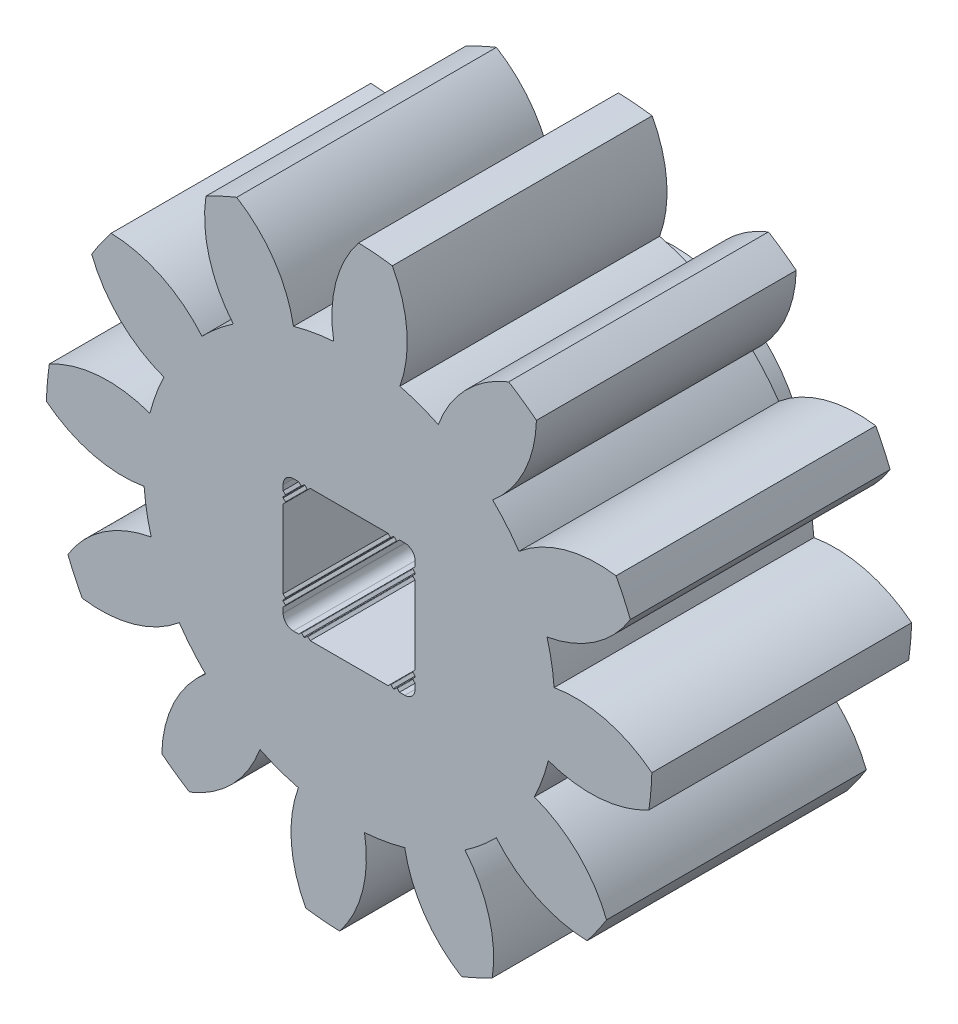
from build123d import *

# Parameters (mm, degrees)
SKETCH1_W            = 7.404
SKETCH1_H            = 6.35
CUT_EXTRUDE1_DEPTH   = 7.35
CUT_EXTRUDE2_DEPTH   = 7.35
CUT_EXTRUDE3_DEPTH   = 7.35
CUT_EXTRUDE4_DEPTH   = 7.35
CUT_EXTRUDE5_DEPTH   = 7.35
CUT_EXTRUDE6_DEPTH   = 7.35
CUT_EXTRUDE7_DEPTH   = 7.35
CUT_EXTRUDE8_DEPTH   = 7.35
CUT_EXTRUDE9_DEPTH   = 7.35
CUT_EXTRUDE10_DEPTH  = 7.35
CUT_EXTRUDE11_DEPTH  = 7.35
CUT_EXTRUDE12_DEPTH  = 7.35
SKETCH15_R           = 3.25
BOSS_EXTRUDE2_DEPTH  = 1.5875
CUT_EXTRUDE13_DEPTH  = 8.9375
FILLET1_R            = 0.0127
CHAMFER1_SIZE        = 0.017960512
CHAMFER2_SIZE        = 0.017990274
CHAMFER2_EDGE_2_SIZE = 0.017990274
CHAMFER2_EDGE_3_SIZE = 0.017990274
CHAMFER2_EDGE_4_SIZE = 0.017990274
FILLET2_R            = 0.25


with BuildPart() as part:
    # Sketch1 → Revolve1 (revolve)
    with BuildSketch(Plane(origin=(0, 0, 0), x_dir=(1, 0, 0), z_dir=(0, 1, 0))):
        with Locations((3.702, 0)):
            Rectangle(SKETCH1_W, SKETCH1_H)
    revolve(axis=Axis((0, 0, -3.175), (0, 0, 1)))

    # Sketch2 → Cut-Extrude1 (cut, through all)
    with BuildSketch(Plane(origin=(0, 0, -3.175), x_dir=(-1, 0, 0), z_dir=(0, 0, -1))):
        with BuildLine():
            ThreePointArc((1.057001873, -7.328162323), (2.532317141, -6.957484164), (3.900741532, -6.293125734))
            ThreePointArc((3.900741532, -6.293125734), (2.850773823, -5.595435975), (2.180140266, -4.527983952))
            ThreePointArc((2.180140266, -4.527983952), (1.71882223, -4.722425266), (1.240447645, -4.870004095))
            ThreePointArc((1.240447645, -4.870004095), (1.41285747, -6.118794727), (1.057001873, -7.328162323))
        make_face()
    extrude(amount=-CUT_EXTRUDE1_DEPTH, mode=Mode.SUBTRACT)

    # Sketch3 → Cut-Extrude2 (cut, through all)
    with BuildSketch(Plane(origin=(0, 0, -3.175), x_dir=(-1, 0, 0), z_dir=(0, 0, -1))):
        with BuildLine():
            ThreePointArc((-2.748690687, -6.874875672), (-1.285691107, -7.291516603), (0.231578393, -7.400377521))
            ThreePointArc((0.231578393, -7.400377521), (-0.328875436, -6.271176611), (-0.375935122, -5.011419263))
            ThreePointArc((-0.375935122, -5.011419263), (-0.872668917, -4.949151363), (-1.360742875, -4.837771086))
            ThreePointArc((-1.360742875, -4.837771086), (-1.835826903, -6.005460409), (-2.748690687, -6.874875672))
        make_face()
    extrude(amount=-CUT_EXTRUDE2_DEPTH, mode=Mode.SUBTRACT)

    # Sketch4 → Cut-Extrude3 (cut, through all)
    with BuildSketch(Plane(origin=(0, 0, -3.175), x_dir=(-1, 0, 0), z_dir=(0, 0, -1))):
        with BuildLine():
            ThreePointArc((-5.817873798, -4.579471636), (-4.759199462, -5.671793057), (-3.499635989, -6.524704127))
            ThreePointArc((-3.499635989, -6.524704127), (-3.420402788, -5.266560539), (-2.831278997, -4.15204883))
            ThreePointArc((-2.831278997, -4.15204883), (-3.230329132, -3.849756349), (-3.597323441, -3.509261221))
            ThreePointArc((-3.597323441, -3.509261221), (-4.592602939, -4.282967824), (-5.817873798, -4.579471636))
        make_face()
    extrude(amount=-CUT_EXTRUDE3_DEPTH, mode=Mode.SUBTRACT)

    # Sketch5 → Cut-Extrude4 (cut, through all)
    with BuildSketch(Plane(origin=(0, 0, -3.175), x_dir=(-1, 0, 0), z_dir=(0, 0, -1))):
        with BuildLine():
            ThreePointArc((-7.328162323, -1.057001873), (-6.957484164, -2.532317141), (-6.293125734, -3.900741532))
            ThreePointArc((-6.293125734, -3.900741532), (-5.595435975, -2.850773823), (-4.527983952, -2.180140266))
            ThreePointArc((-4.527983952, -2.180140266), (-4.722425266, -1.71882223), (-4.870004095, -1.240447645))
            ThreePointArc((-4.870004095, -1.240447645), (-6.118794727, -1.41285747), (-7.328162323, -1.057001873))
        make_face()
    extrude(amount=-CUT_EXTRUDE4_DEPTH, mode=Mode.SUBTRACT)

    # Sketch6 → Cut-Extrude5 (cut, through all)
    with BuildSketch(Plane(origin=(0, 0, -3.175), x_dir=(-1, 0, 0), z_dir=(0, 0, -1))):
        with BuildLine():
            ThreePointArc((-6.874875672, 2.748690687), (-7.291516603, 1.285691107), (-7.400377521, -0.231578393))
            ThreePointArc((-7.400377521, -0.231578393), (-6.271176611, 0.328875436), (-5.011419263, 0.375935122))
            ThreePointArc((-5.011419263, 0.375935122), (-4.949151363, 0.872668917), (-4.837771086, 1.360742875))
            ThreePointArc((-4.837771086, 1.360742875), (-6.005460409, 1.835826903), (-6.874875672, 2.748690687))
        make_face()
    extrude(amount=-CUT_EXTRUDE5_DEPTH, mode=Mode.SUBTRACT)

    # Sketch7 → Cut-Extrude6 (cut, through all)
    with BuildSketch(Plane(origin=(0, 0, -3.175), x_dir=(-1, 0, 0), z_dir=(0, 0, -1))):
        with BuildLine():
            ThreePointArc((-4.579471636, 5.817873798), (-5.671793057, 4.759199462), (-6.524704127, 3.499635989))
            ThreePointArc((-6.524704127, 3.499635989), (-5.266560539, 3.420402788), (-4.15204883, 2.831278997))
            ThreePointArc((-4.15204883, 2.831278997), (-3.849756349, 3.230329132), (-3.509261221, 3.597323441))
            ThreePointArc((-3.509261221, 3.597323441), (-4.282967824, 4.592602939), (-4.579471636, 5.817873798))
        make_face()
    extrude(amount=-CUT_EXTRUDE6_DEPTH, mode=Mode.SUBTRACT)

    # Sketch8 → Cut-Extrude7 (cut, through all)
    with BuildSketch(Plane(origin=(0, 0, -3.175), x_dir=(-1, 0, 0), z_dir=(0, 0, -1))):
        with BuildLine():
            ThreePointArc((-1.057001873, 7.328162323), (-2.532317141, 6.957484164), (-3.900741532, 6.293125734))
            ThreePointArc((-3.900741532, 6.293125734), (-2.850773823, 5.595435975), (-2.180140266, 4.527983952))
            ThreePointArc((-2.180140266, 4.527983952), (-1.71882223, 4.722425266), (-1.240447645, 4.870004095))
            ThreePointArc((-1.240447645, 4.870004095), (-1.41285747, 6.118794727), (-1.057001873, 7.328162323))
        make_face()
    extrude(amount=-CUT_EXTRUDE7_DEPTH, mode=Mode.SUBTRACT)

    # Sketch9 → Cut-Extrude8 (cut, through all)
    with BuildSketch(Plane(origin=(0, 0, -3.175), x_dir=(-1, 0, 0), z_dir=(0, 0, -1))):
        with BuildLine():
            ThreePointArc((2.748690687, 6.874875672), (1.285691107, 7.291516603), (-0.231578393, 7.400377521))
            ThreePointArc((-0.231578393, 7.400377521), (0.328875436, 6.271176611), (0.375935122, 5.011419263))
            ThreePointArc((0.375935122, 5.011419263), (0.872668917, 4.949151363), (1.360742875, 4.837771086))
            ThreePointArc((1.360742875, 4.837771086), (1.835826903, 6.005460409), (2.748690687, 6.874875672))
        make_face()
    extrude(amount=-CUT_EXTRUDE8_DEPTH, mode=Mode.SUBTRACT)

    # Sketch10 → Cut-Extrude9 (cut, through all)
    with BuildSketch(Plane(origin=(0, 0, -3.175), x_dir=(-1, 0, 0), z_dir=(0, 0, -1))):
        with BuildLine():
            ThreePointArc((5.817873798, 4.579471636), (4.759199462, 5.671793057), (3.499635989, 6.524704127))
            ThreePointArc((3.499635989, 6.524704127), (3.420402788, 5.266560539), (2.831278997, 4.15204883))
            ThreePointArc((2.831278997, 4.15204883), (3.230329132, 3.849756349), (3.597323441, 3.509261221))
            ThreePointArc((3.597323441, 3.509261221), (4.592602939, 4.282967824), (5.817873798, 4.579471636))
        make_face()
    extrude(amount=-CUT_EXTRUDE9_DEPTH, mode=Mode.SUBTRACT)

    # Sketch11 → Cut-Extrude10 (cut, through all)
    with BuildSketch(Plane(origin=(0, 0, -3.175), x_dir=(-1, 0, 0), z_dir=(0, 0, -1))):
        with BuildLine():
            ThreePointArc((7.328162323, 1.057001873), (6.957484164, 2.532317141), (6.293125734, 3.900741532))
            ThreePointArc((6.293125734, 3.900741532), (5.595435975, 2.850773823), (4.527983952, 2.180140266))
            ThreePointArc((4.527983952, 2.180140266), (4.722425266, 1.71882223), (4.870004095, 1.240447645))
            ThreePointArc((4.870004095, 1.240447645), (6.118794727, 1.41285747), (7.328162323, 1.057001873))
        make_face()
    extrude(amount=-CUT_EXTRUDE10_DEPTH, mode=Mode.SUBTRACT)

    # Sketch12 → Cut-Extrude11 (cut, through all)
    with BuildSketch(Plane(origin=(0, 0, -3.175), x_dir=(-1, 0, 0), z_dir=(0, 0, -1))):
        with BuildLine():
            ThreePointArc((6.874875672, -2.748690687), (7.291516603, -1.285691107), (7.400377521, 0.231578393))
            ThreePointArc((7.400377521, 0.231578393), (6.271176611, -0.328875436), (5.011419263, -0.375935122))
            ThreePointArc((5.011419263, -0.375935122), (4.949151363, -0.872668917), (4.837771086, -1.360742875))
            ThreePointArc((4.837771086, -1.360742875), (6.005460409, -1.835826903), (6.874875672, -2.748690687))
        make_face()
    extrude(amount=-CUT_EXTRUDE11_DEPTH, mode=Mode.SUBTRACT)

    # Sketch13 → Cut-Extrude12 (cut, through all)
    with BuildSketch(Plane(origin=(0, 0, -3.175), x_dir=(-1, 0, 0), z_dir=(0, 0, -1))):
        with BuildLine():
            ThreePointArc((4.579471636, -5.817873798), (5.671793057, -4.759199462), (6.524704127, -3.499635989))
            ThreePointArc((6.524704127, -3.499635989), (5.266560539, -3.420402788), (4.15204883, -2.831278997))
            ThreePointArc((4.15204883, -2.831278997), (3.849756349, -3.230329132), (3.509261221, -3.597323441))
            ThreePointArc((3.509261221, -3.597323441), (4.282967824, -4.592602939), (4.579471636, -5.817873798))
        make_face()
    extrude(amount=-CUT_EXTRUDE12_DEPTH, mode=Mode.SUBTRACT)

    # Sketch15 → Boss-Extrude2 (add)
    with BuildSketch(Plane(origin=(0, 0, -3.175), x_dir=(-1, 0, 0), z_dir=(0, 0, -1))):
        Circle(SKETCH15_R)
    extrude(amount=BOSS_EXTRUDE2_DEPTH)

    # Sketch16 → Cut-Extrude13 (cut, through all)
    with BuildSketch(Plane(origin=(0, 0, -4.7625), x_dir=(-1, 0, 0), z_dir=(0, 0, -1))):
        Polygon((1.548789697, 1.168210303), (1.6125, 1.2315), (1.6125, 1.6125), (1.2315, 1.6125), (1.168, 1.549), (1.0918, 1.6252), (1.0156, 1.549), (0.9521, 1.6125), (-0.9521, 1.6125), (-1.0156, 1.548789726), (-1.0918, 1.625242055), (-1.168, 1.548789726), (-1.2315, 1.6125), (-1.6125, 1.6125), (-1.6125, 1.2315), (-1.548789726, 1.168), (-1.625242055, 1.0918), (-1.548789726, 1.0156), (-1.6125, 0.9521), (-1.6125, -0.9521), (-1.549, -1.0156), (-1.6252, -1.0918), (-1.548789697, -1.168210303), (-1.6125, -1.2315), (-1.6125, -1.6125), (-1.2315, -1.6125), (-1.168, -1.549), (-1.0918, -1.6252), (-1.0156, -1.549), (-0.9521, -1.6125), (0.9521, -1.6125), (1.0156, -1.548789726), (1.0918, -1.625242055), (1.168, -1.548789726), (1.2315, -1.6125), (1.6125, -1.6125), (1.6125, -1.2315), (1.548789726, -1.168), (1.625242055, -1.0918), (1.548789726, -1.0156), (1.6125, -0.9521), (1.6125, 0.9521), (1.549, 1.0156), (1.6252, 1.0918), align=None)
    extrude(amount=-CUT_EXTRUDE13_DEPTH, mode=Mode.SUBTRACT)

    # Fillet1
    fillet1_edges = [part.edges().sort_by_distance(p)[0] for p in [
        (-1.548789697, 1.168210303, -0.79375),
        (-1.549, 1.0156, -0.79375),
        (-1.548789726, -1.0156, -0.79375),
        (-1.548789726, -1.168, -0.79375),
        (-1.168, -1.548789726, -0.79375),
        (-1.0156, -1.548789726, -0.79375),
        (1.0156, -1.549, -0.79375),
        (1.168, -1.549, -0.79375),
        (1.548789697, -1.168210303, -0.79375),
        (1.549, -1.0156, -0.79375),
        (1.548789726, 1.0156, -0.79375),
        (1.548789726, 1.168, -0.79375),
        (1.168, 1.548789726, -0.79375),
        (1.0156, 1.548789726, -0.79375),
        (-1.0156, 1.549, -0.79375),
        (-1.168, 1.549, -0.79375),
    ]]
    fillet(fillet1_edges, radius=FILLET1_R)

    # Chamfer1
    chamfer1_edges = [part.edges().sort_by_distance(p)[0] for p in [
        (-1.6252, 1.0918, -0.79375),
        (1.0918, -1.6252, -0.79375),
        (1.6252, -1.0918, -0.79375),
        (-1.0918, 1.6252, -0.79375),
    ]]
    chamfer(chamfer1_edges, length=CHAMFER1_SIZE)

    # Chamfer2
    chamfer2_edges = [part.edges().sort_by_distance(p)[0] for p in [
        (-1.625242055, -1.0918, -0.79375),
    ]]
    chamfer(chamfer2_edges, length=CHAMFER2_SIZE)

    # Chamfer2 edge 2
    chamfer2_edge_2_edges = [part.edges().sort_by_distance(p)[0] for p in [
        (-1.0918, -1.625242055, -0.79375),
    ]]
    chamfer(chamfer2_edge_2_edges, length=CHAMFER2_EDGE_2_SIZE)

    # Chamfer2 edge 3
    chamfer2_edge_3_edges = [part.edges().sort_by_distance(p)[0] for p in [
        (1.625242055, 1.0918, -0.79375),
    ]]
    chamfer(chamfer2_edge_3_edges, length=CHAMFER2_EDGE_3_SIZE)

    # Chamfer2 edge 4
    chamfer2_edge_4_edges = [part.edges().sort_by_distance(p)[0] for p in [
        (1.0918, 1.625242055, -0.79375),
    ]]
    chamfer(chamfer2_edge_4_edges, length=CHAMFER2_EDGE_4_SIZE)

    # Fillet2
    fillet2_edges = [part.edges().sort_by_distance(p)[0] for p in [
        (-1.6125, -1.6125, -0.79375),
        (1.6125, -1.6125, -0.79375),
        (1.6125, 1.6125, -0.79375),
        (-1.6125, 1.6125, -0.79375),
    ]]
    fillet(fillet2_edges, radius=FILLET2_R)


solid = part.part
